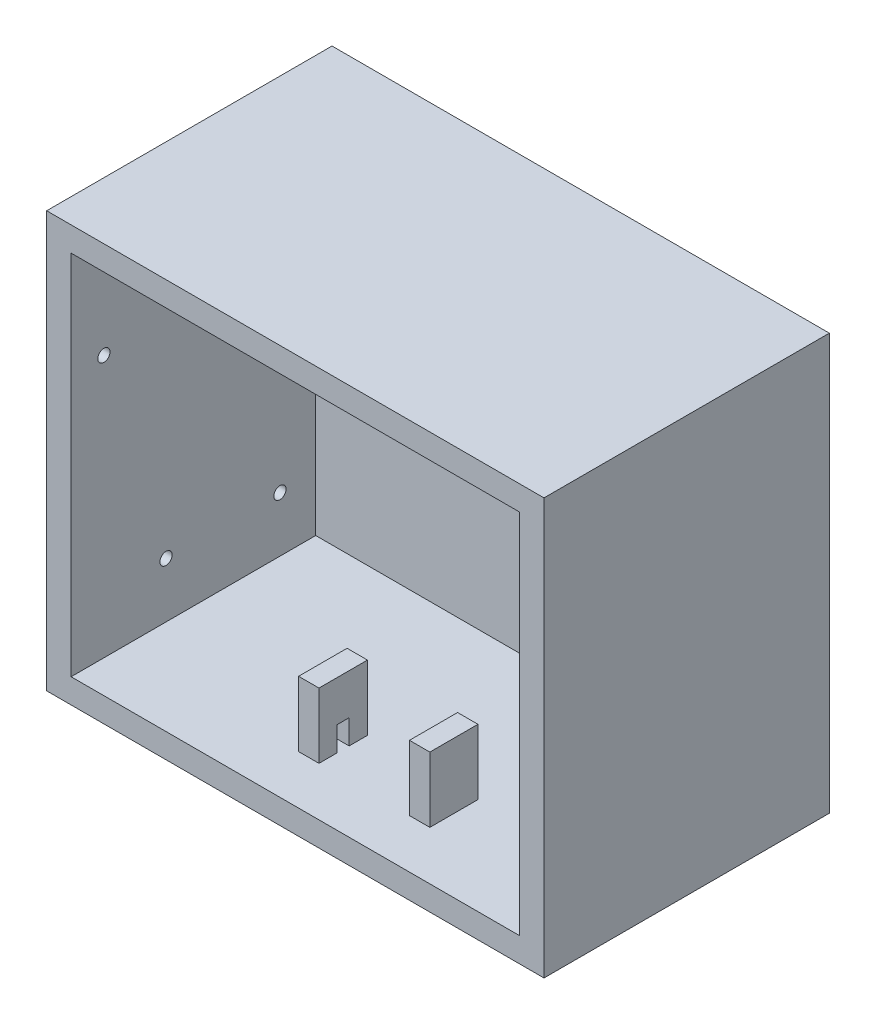
from build123d import *

# Parameters (mm, degrees)
SKETCH1_W           = 122
SKETCH1_H           = 102
SKETCH1_W_2         = 110
SKETCH1_H_2         = 90
BOSS_EXTRUDE1_DEPTH = 70
SKETCH3_W           = 10
SKETCH3_H           = 102
BOSS_EXTRUDE3_DEPTH = 122
SKETCH6_R           = 1.5
CUT_EXTRUDE1_DEPTH  = 10
SKETCH5_R           = 1.5
CUT_EXTRUDE2_DEPTH  = 10
SKETCH5_3_R         = 1.5
CUT_EXTRUDE3_DEPTH  = 10
SKETCH8_W           = 5
SKETCH8_H           = 11.8
SKETCH8_H_2         = 11.897582895
BOSS_EXTRUDE4_DEPTH = 22
SKETCH14_W          = 3
SKETCH14_H          = 6
CUT_EXTRUDE6_DEPTH  = 10


with BuildPart() as part:
    # Sketch1 → Boss-Extrude1 (new body)
    with BuildSketch(Plane.XY):
        Rectangle(SKETCH1_W, SKETCH1_H)
        Rectangle(SKETCH1_W_2, SKETCH1_H_2, mode=Mode.SUBTRACT)
    extrude(amount=BOSS_EXTRUDE1_DEPTH)

    # Sketch3 → Boss-Extrude3 (add)
    with BuildSketch(Plane(origin=(61, 0, 0), x_dir=(0, 0, -1), z_dir=(1, 0, 0))):
        with Locations((-5, 0)):
            Rectangle(SKETCH3_W, SKETCH3_H)
    extrude(amount=-BOSS_EXTRUDE3_DEPTH)

    # Sketch6 → Cut-Extrude1 (cut)
    with BuildSketch(Plane.ZY.offset(61)):
        with Locations((18.78, -31.5)):
            Circle(SKETCH6_R)
        with Locations((46.72, -31.5)):
            Circle(SKETCH6_R)
    extrude(amount=-CUT_EXTRUDE1_DEPTH, mode=Mode.SUBTRACT)

    # Sketch5 → Cut-Extrude2 (cut)
    with BuildSketch(Plane.ZY.offset(61)):
        with Locations((61.96, 19.26)):
            Circle(SKETCH5_R)
    extrude(amount=-CUT_EXTRUDE2_DEPTH, mode=Mode.SUBTRACT)

    # Sketch5_3 → Cut-Extrude3 (cut)
    with BuildSketch(Plane.ZY.offset(61)):
        with Locations((13.7, 19.26)):
            Circle(SKETCH5_3_R)
    extrude(amount=-CUT_EXTRUDE3_DEPTH, mode=Mode.SUBTRACT)

    # Sketch8 → Boss-Extrude4 (add)
    with BuildSketch(Plane.XZ.offset(51)):
        with Locations((18.5, 52.1)):
            Rectangle(SKETCH8_W, SKETCH8_H)
        with Locations((-8.7, 52.051208553)):
            Rectangle(SKETCH8_W, SKETCH8_H_2)
    extrude(amount=-BOSS_EXTRUDE4_DEPTH)

    # Sketch14 → Cut-Extrude6 (cut)
    with BuildSketch(Plane.ZY.offset(11.2)):
        with Locations((52.1, -42)):
            Rectangle(SKETCH14_W, SKETCH14_H)
    extrude(amount=-CUT_EXTRUDE6_DEPTH, mode=Mode.SUBTRACT)


solid = part.part
